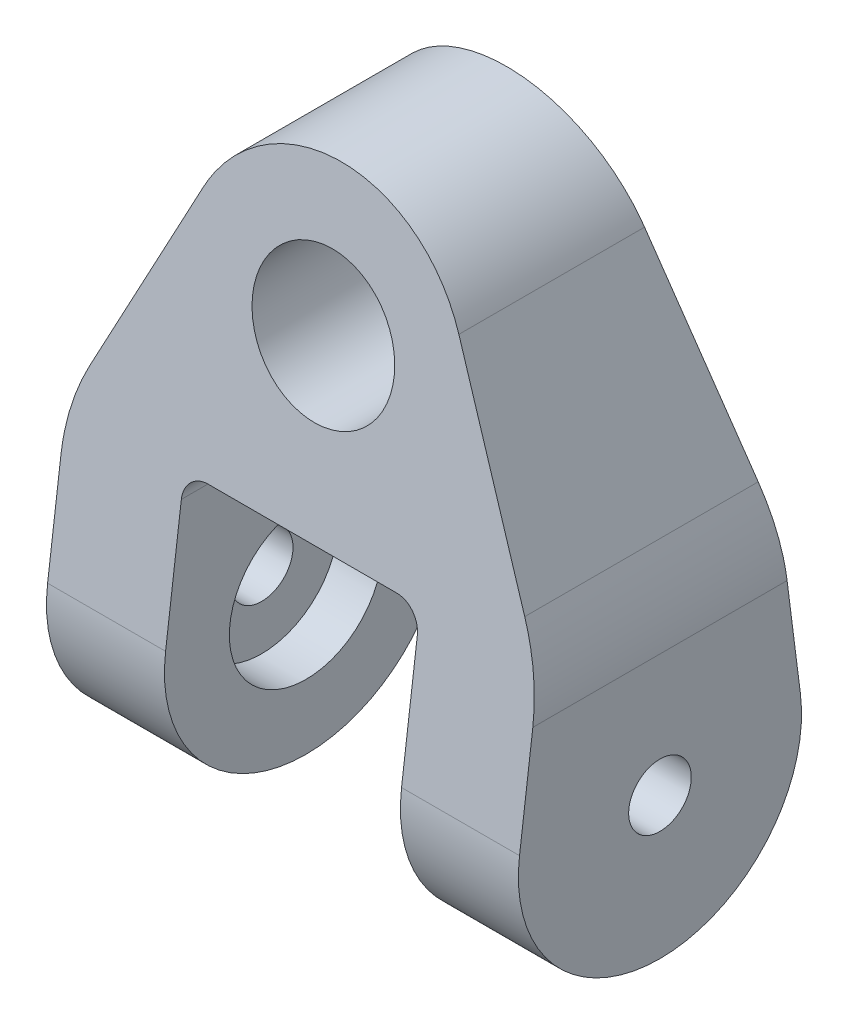
from build123d import *

# Parameters (mm, degrees)
SKETCH1_R                                 = 9.525
BOSS_EXTRUDE1_DEPTH                       = 19.05
SKETCH2_OUTSIDE_W                         = 62.28
SKETCH2_OUTSIDE_H                         = 106.73
CUT_EXTRUDE1_DEPTH                        = 31.75
FILLET1_R                                 = 3.175
FILLET2_R                                 = 25.4
CBORE_FOR_5_16_HEX_CAP_SCREW1_D           = 8.4328
CBORE_FOR_5_16_HEX_CAP_SCREW1_DEPTH       = 15.875
CBORE_FOR_5_16_HEX_CAP_SCREW1_CBORE_D     = 20.6375
CBORE_FOR_5_16_HEX_CAP_SCREW1_CBORE_DEPTH = 5.969


with BuildPart() as part:
    # Sketch1 → Boss-Extrude1 (new body, symmetric)
    with BuildSketch(Plane.XY):
        with BuildLine():
            Line((17.184764726, 8.221092465), (31.75, -22.225))
            Line((31.75, -22.225), (31.75, -63.5))
            Line((31.75, -63.5), (15.875, -63.5))
            Line((15.875, -63.5), (15.875, -22.225))
            Line((15.875, -22.225), (-15.875, -22.225))
            Line((-15.875, -22.225), (-15.875, -63.5))
            Line((-15.875, -63.5), (-31.75, -63.5))
            Line((-31.75, -63.5), (-31.75, -22.225))
            Line((-31.75, -22.225), (-17.184764726, 8.221092465))
            ThreePointArc((-17.184764726, 8.221092465), (0, 19.05), (17.184764726, 8.221092465))
        make_face()
        Circle(SKETCH1_R, mode=Mode.SUBTRACT)
    extrude(amount=BOSS_EXTRUDE1_DEPTH, both=True)

    # Sketch2 outside → Cut-Extrude1 (cut, symmetric)
    with BuildSketch(Plane(origin=(0, 0, 0), x_dir=(0, 0, -1), z_dir=(1, 0, 0))):
        with Locations((0, -22.225)):
            Rectangle(SKETCH2_OUTSIDE_W, SKETCH2_OUTSIDE_H)
        with BuildLine():
            Line((18.897197735, -42.042009604), (11.1125, 19.05))
            Line((11.1125, 19.05), (-11.1125, 19.05))
            Line((-11.1125, 19.05), (-18.897197735, -42.042009604))
            ThreePointArc((-18.897197735, -42.042009604), (0, -63.5), (18.897197735, -42.042009604))
        make_face(mode=Mode.SUBTRACT)
    extrude(amount=CUT_EXTRUDE1_DEPTH, both=True, mode=Mode.SUBTRACT)

    # Fillet1
    fillet1_edges = [part.edges().sort_by_distance(p)[0] for p in [
        (15.875, -22.225, 0),
        (-15.875, -22.225, 0),
    ]]
    fillet(fillet1_edges, radius=FILLET1_R)

    # Fillet2
    fillet2_edges = [part.edges().sort_by_distance(p)[0] for p in [
        (31.75, -22.225, 0),
        (-31.75, -22.225, 0),
    ]]
    fillet(fillet2_edges, radius=FILLET2_R)

    # CBORE for 5/16 Hex Cap Screw1
    with Locations(Plane(origin=(-15.875, 0, 0), x_dir=(0, 0, -1), z_dir=(1, 0, 0))):
        with Locations((0, -44.45)):
            cbore_for_5_16_hex_cap_screw1 = CounterBoreHole(CBORE_FOR_5_16_HEX_CAP_SCREW1_D / 2, CBORE_FOR_5_16_HEX_CAP_SCREW1_CBORE_D / 2, CBORE_FOR_5_16_HEX_CAP_SCREW1_CBORE_DEPTH, depth=CBORE_FOR_5_16_HEX_CAP_SCREW1_DEPTH)

    # Mirror1: CBORE for 5/16 Hex Cap Screw1 across plane
    add(cbore_for_5_16_hex_cap_screw1.mirror(Plane(origin=(0, 0, 0), x_dir=(0, 0, 1), z_dir=(1, 0, 0))), mode=Mode.SUBTRACT)


solid = part.part
